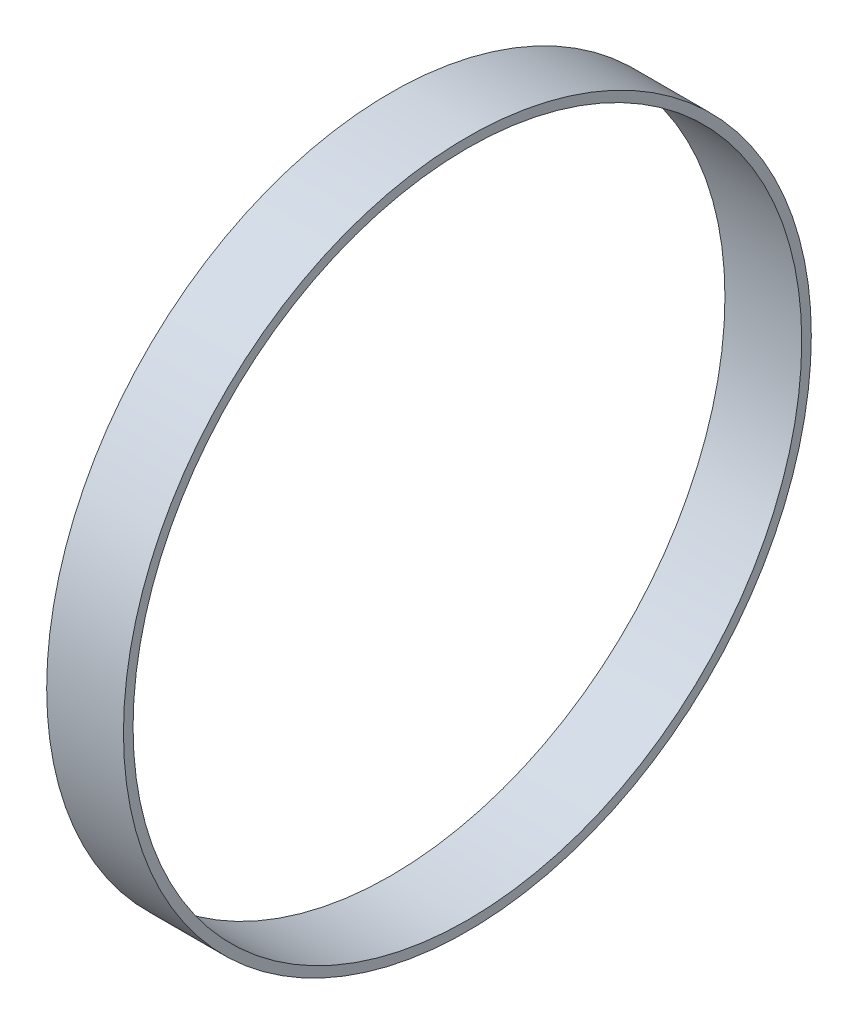
from build123d import *

# Parameters (mm, degrees)
SKETCH_1_W = 24
SKETCH_1_H = 3


with BuildPart() as part:
    # Эскиз1 → Повернуть1 (revolve)
    with BuildSketch(Plane.XY):
        with Locations((-12, 106)):
            Rectangle(SKETCH_1_W, SKETCH_1_H)
    revolve(axis=Axis((0, 0, 0), (-1, 0, 0)))


solid = part.part
